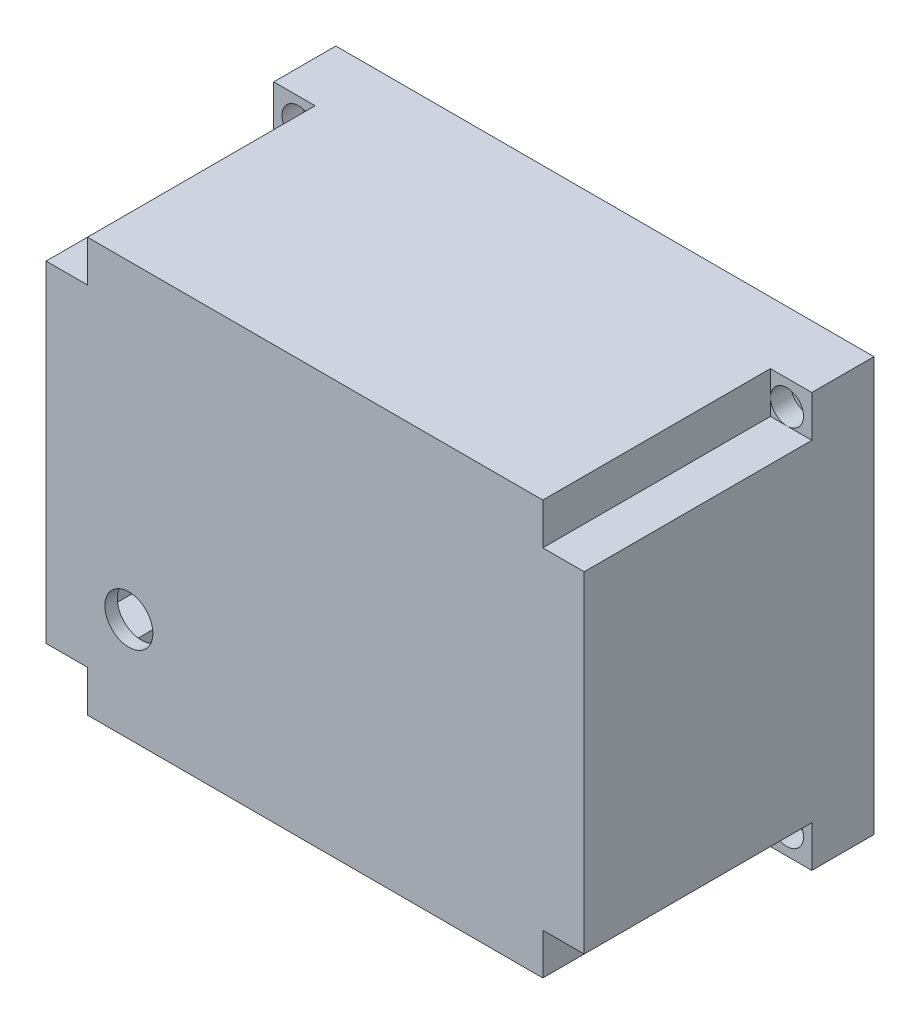
from build123d import *

# Parameters (mm, degrees)
SKETCH2_W           = 130
SKETCH2_H           = 70
BOSS_EXTRUDE1_DEPTH = 100
SKETCH3_W           = 104
SKETCH3_H           = 74
CUT_EXTRUDE1_DEPTH  = 67
SKETCH4_W           = 10
SKETCH4_H           = 10
CUT_EXTRUDE2_DEPTH  = 55
SKETCH5_W           = 104
SKETCH5_H           = 10
CUT_EXTRUDE3_DEPTH  = 67
SKETCH6_W           = 10
SKETCH6_H           = 74
CUT_EXTRUDE4_DEPTH  = 67
SKETCH9_R           = 1.75
CUT_EXTRUDE5_DEPTH  = 67
SKETCH10_R          = 4
CUT_EXTRUDE6_DEPTH  = 5
SKETCH12_R          = 4
CUT_EXTRUDE7_DEPTH  = 5
SKETCH13_R          = 4
CUT_EXTRUDE8_DEPTH  = 5
SKETCH14_R          = 4
CUT_EXTRUDE9_DEPTH  = 5
SKETCH15_W          = 3
SKETCH15_H          = 3
BOSS_EXTRUDE2_DEPTH = 5
SKETCH16_W          = 76
SKETCH16_H          = 3
BOSS_EXTRUDE3_DEPTH = 15
SKETCH17_W          = 3
SKETCH17_H          = 30
BOSS_EXTRUDE4_DEPTH = 15
SKETCH18_R          = 5.8
CUT_EXTRUDE10_DEPTH = 15


with BuildPart() as part:
    # Sketch2 → Boss-Extrude1 (new body)
    with BuildSketch(Plane(origin=(0, 0, 0), x_dir=(1, 0, 0), z_dir=(0, 1, 0))):
        with Locations((65, 35)):
            Rectangle(SKETCH2_W, SKETCH2_H)
    extrude(amount=BOSS_EXTRUDE1_DEPTH)

    # Sketch3 → Cut-Extrude1 (cut)
    with BuildSketch(Plane(origin=(0, 0, -70), x_dir=(-1, 0, 0), z_dir=(0, 0, -1))):
        with Locations((-65, 50)):
            Rectangle(SKETCH3_W, SKETCH3_H)
    extrude(amount=-CUT_EXTRUDE1_DEPTH, mode=Mode.SUBTRACT)

    # Sketch4 → Cut-Extrude2 (cut)
    with BuildSketch(Plane.XY):
        with Locations((5, 95)):
            Rectangle(SKETCH4_W, SKETCH4_H)
        with Locations((125, 95)):
            Rectangle(SKETCH4_W, SKETCH4_H)
        with Locations((5, 5)):
            Rectangle(SKETCH4_W, SKETCH4_H)
        with Locations((125, 5)):
            Rectangle(SKETCH4_W, SKETCH4_H)
    extrude(amount=-CUT_EXTRUDE2_DEPTH, mode=Mode.SUBTRACT)

    # Sketch5 → Cut-Extrude3 (cut)
    with BuildSketch(Plane(origin=(0, 0, -70), x_dir=(-1, 0, 0), z_dir=(0, 0, -1))):
        with Locations((-65, 92)):
            Rectangle(SKETCH5_W, SKETCH5_H)
        with Locations((-65, 8)):
            Rectangle(SKETCH5_W, SKETCH5_H)
    extrude(amount=-CUT_EXTRUDE3_DEPTH, mode=Mode.SUBTRACT)

    # Sketch6 → Cut-Extrude4 (cut)
    with BuildSketch(Plane(origin=(0, 0, -70), x_dir=(-1, 0, 0), z_dir=(0, 0, -1))):
        with Locations((-122, 50)):
            Rectangle(SKETCH6_W, SKETCH6_H)
        with Locations((-8, 50)):
            Rectangle(SKETCH6_W, SKETCH6_H)
    extrude(amount=-CUT_EXTRUDE4_DEPTH, mode=Mode.SUBTRACT)

    # Sketch9 → Cut-Extrude5 (cut)
    with BuildSketch(Plane(origin=(0, 0, -70), x_dir=(-1, 0, 0), z_dir=(0, 0, -1))):
        with Locations((-124, 94)):
            Circle(SKETCH9_R)
        with Locations((-124, 6)):
            Circle(SKETCH9_R)
        with Locations((-6, 94)):
            Circle(SKETCH9_R)
        with Locations((-6, 6)):
            Circle(SKETCH9_R)
    extrude(amount=-CUT_EXTRUDE5_DEPTH, mode=Mode.SUBTRACT)

    # Sketch10 → Cut-Extrude6 (cut)
    with BuildSketch(Plane.XY.offset(-55)):
        with Locations((124, 94)):
            Circle(SKETCH10_R)
    extrude(amount=-CUT_EXTRUDE6_DEPTH, mode=Mode.SUBTRACT)

    # Sketch12 → Cut-Extrude7 (cut)
    with BuildSketch(Plane.XY.offset(-55)):
        with Locations((124, 6)):
            Circle(SKETCH12_R)
    extrude(amount=-CUT_EXTRUDE7_DEPTH, mode=Mode.SUBTRACT)

    # Sketch13 → Cut-Extrude8 (cut)
    with BuildSketch(Plane.XY.offset(-55)):
        with Locations((6, 6)):
            Circle(SKETCH13_R)
    extrude(amount=-CUT_EXTRUDE8_DEPTH, mode=Mode.SUBTRACT)

    # Sketch14 → Cut-Extrude9 (cut)
    with BuildSketch(Plane.XY.offset(-55)):
        with Locations((6, 94)):
            Circle(SKETCH14_R)
    extrude(amount=-CUT_EXTRUDE9_DEPTH, mode=Mode.SUBTRACT)

    # Sketch15 → Boss-Extrude2 (add)
    with BuildSketch(Plane(origin=(0, 0, -70), x_dir=(-1, 0, 0), z_dir=(0, 0, -1))):
        with Locations((-118.5, 88.5)):
            Rectangle(SKETCH15_W, SKETCH15_H)
        with Locations((-118.5, 11.5)):
            Rectangle(SKETCH15_W, SKETCH15_H)
        with Locations((-11.5, 11.5)):
            Rectangle(SKETCH15_W, SKETCH15_H)
        with Locations((-11.5, 88.5)):
            Rectangle(SKETCH15_W, SKETCH15_H)
    extrude(amount=BOSS_EXTRUDE2_DEPTH)

    # Sketch16 → Boss-Extrude3 (add)
    with BuildSketch(Plane(origin=(0, 3, 0), x_dir=(1, 0, 0), z_dir=(0, 1, 0))):
        with Locations((79, 68.5)):
            Rectangle(SKETCH16_W, SKETCH16_H)
    extrude(amount=BOSS_EXTRUDE3_DEPTH)

    # Sketch17 → Boss-Extrude4 (add)
    with BuildSketch(Plane(origin=(0, 0, -3), x_dir=(-1, 0, 0), z_dir=(0, 0, -1))):
        with Locations((-99.5, 33)):
            Rectangle(SKETCH17_W, SKETCH17_H)
        with Locations((-36.5, 33)):
            Rectangle(SKETCH17_W, SKETCH17_H)
    extrude(amount=BOSS_EXTRUDE4_DEPTH)

    # Sketch18 → Cut-Extrude10 (cut)
    with BuildSketch(Plane(origin=(0, 0, -3), x_dir=(-1, 0, 0), z_dir=(0, 0, -1))):
        with Locations((-20, 25)):
            Circle(SKETCH18_R)
    extrude(amount=-CUT_EXTRUDE10_DEPTH, mode=Mode.SUBTRACT)


solid = part.part
